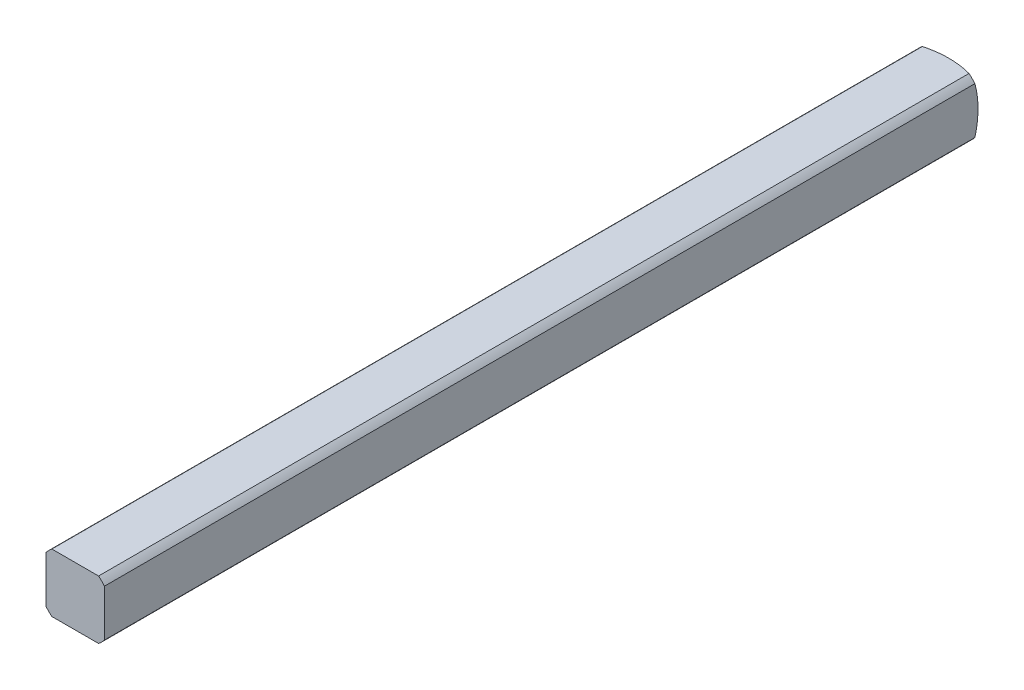
from build123d import *

# Parameters (mm, degrees)
SKETCH1_W           = 3.175
SKETCH1_H           = 3.175
BOSS_EXTRUDE1_DEPTH = 25.4
SKETCH2_OUTSIDE_W   = 10.334
SKETCH2_OUTSIDE_H   = 10.334
SKETCH2_OUTSIDE_R   = 2.032
CUT_EXTRUDE1_DEPTH  = 26.4
CUT_EXTRUDE3_DEPTH  = 4.175


with BuildPart() as part:
    # Sketch1 → Boss-Extrude1 (new body)
    with BuildSketch(Plane.XY):
        Rectangle(SKETCH1_W, SKETCH1_H)
    extrude(amount=BOSS_EXTRUDE1_DEPTH)

    # Sketch2 outside → Cut-Extrude1 (cut, through all)
    with BuildSketch(Plane(origin=(0, 0, 0), x_dir=(-1, 0, 0), z_dir=(0, 0, -1))):
        Rectangle(SKETCH2_OUTSIDE_W, SKETCH2_OUTSIDE_H)
        Circle(SKETCH2_OUTSIDE_R, mode=Mode.SUBTRACT)
    extrude(amount=-CUT_EXTRUDE1_DEPTH, mode=Mode.SUBTRACT)

    # Sketch3 → Cut-Revolve1 (revolve, cut)
    with BuildSketch(Plane(origin=(0, 0, 0), x_dir=(1, 0, 0), z_dir=(0, 1, 0))):
        with BuildLine():
            Line((-5.053685963, -4.40273269), (-5.053685963, 5.740530545))
            Line((-5.053685963, 5.740530545), (0, 5.740530545))
            Line((0, 5.740530545), (0, 0.160877736))
            ThreePointArc((0, 0.160877736), (-3.404639553, -1.148866368), (-5.053685963, -4.40273269))
        make_face()
    revolve(axis=Axis((0, 0, 25.4), (0, 0, -1)), mode=Mode.SUBTRACT)

    # Mirror1: part across plane


with BuildPart() as part_1:
    add(part.part)
    add(part.part.mirror(Plane(origin=(0, 0, 25.4), x_dir=(1, 0, 0), z_dir=(0, 0, -1))))

    # Sketch5 → Cut-Extrude3 (cut, through all)
    with BuildSketch(Plane(origin=(1.5875, 0, 0), x_dir=(0, 0, -1), z_dir=(1, 0, 0))):
        Polygon((-50.706459955, -1.5875), (-47.531459955, -1.5875), (-47.531459955, 1.5875), (-50.706459955, 1.5875), (-51.039784271, 1.5875), (-51.039784271, -1.5875), align=None)
    extrude(amount=-CUT_EXTRUDE3_DEPTH, mode=Mode.SUBTRACT)


solid = part_1.part
